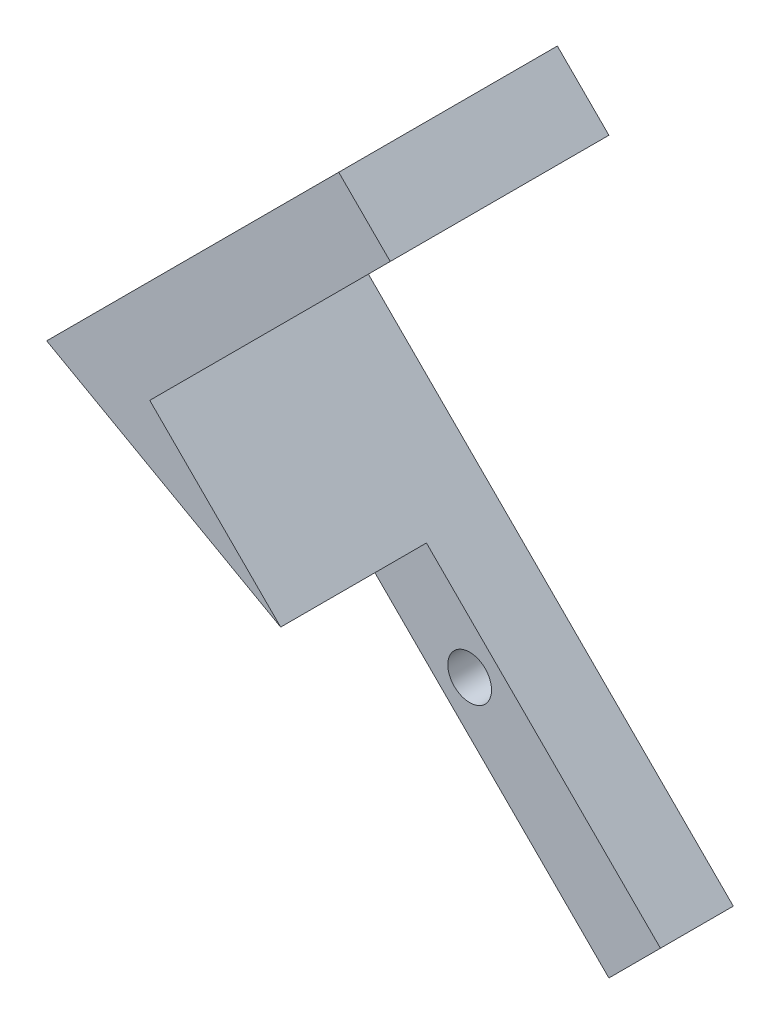
from build123d import *

# Parameters (mm, degrees)
EXTRUDE_1_DEPTH     = 10
SKETCH_2_R          = 1.5
CUT_EXTRUDE_1_DEPTH = 10
SKETCH_3_R          = 1.5
CUT_EXTRUDE_4_DEPTH = 5
SKETCH_4_W          = 5
SKETCH_4_H          = 5
CUT_EXTRUDE_5_DEPTH = 5
EXTRUDE_2_DEPTH     = 5


with BuildPart() as part:
    # 草图1 → 凸台-拉伸1 (new body)
    with BuildSketch(Plane.XY):
        Polygon((-23.571067812, 16.5), (5, -12.071067812), (8.535533906, -8.535533906), (6.051882873, -6.051882873), (0, 0), (-16.5, 16.5), (0, 33), (-3.535533906, 36.535533906), align=None)
    extrude(amount=EXTRUDE_1_DEPTH)

    # 草图2 → 切除-拉伸1 (cut)
    with BuildSketch(Plane.XY.offset(10)):
        with Locations((-4.550561614, 1.015027708)):
            Circle(SKETCH_2_R)
    extrude(amount=-CUT_EXTRUDE_1_DEPTH, mode=Mode.SUBTRACT)

    # 草图3 → 切除-拉伸4 (cut)
    with BuildSketch(Plane.XY.offset(10)):
        Polygon((-1.596461706, 6.368004388), (-3.982233047, 3.982233047), (8.535533906, -8.535533906), (5, -12.071067812), (-7.517766953, 0.446699141), (-9.33715939, -1.372693296), (6.144235978, -17.323833909), (15.036478659, -7.320060893), align=None)
        Polygon((8.535533906, -8.535533906), (-3.982233047, 3.982233047), (-4.279030417, 3.685435677), (-7.517766953, 0.446699141), (5, -12.071067812), align=None)
        with Locations((-4.550561614, 1.015027708)):
            Circle(SKETCH_3_R, mode=Mode.SUBTRACT)
    extrude(amount=-CUT_EXTRUDE_4_DEPTH, mode=Mode.SUBTRACT)

    # 草图4 → 切除-拉伸5 (cut)
    with BuildSketch(Plane(origin=(-3.982233047, 3.982233047, 0), x_dir=(0, 0, -1), z_dir=(0.707106781, -0.707106781, 0))):
        with Locations((-7.5, -2.5)):
            Rectangle(SKETCH_4_W, SKETCH_4_H)
    extrude(amount=-CUT_EXTRUDE_5_DEPTH, mode=Mode.SUBTRACT)

    # 草图5 → 凸台-拉伸2 (add)
    with BuildSketch(Plane.XY.offset(10)):
        Polygon((-7.517766953, 7.517766953), (-23.571067812, 16.5), (-3.535533906, 36.535533906), (0, 33), (-16.5, 16.5), align=None)
    extrude(amount=EXTRUDE_2_DEPTH)


solid = part.part
